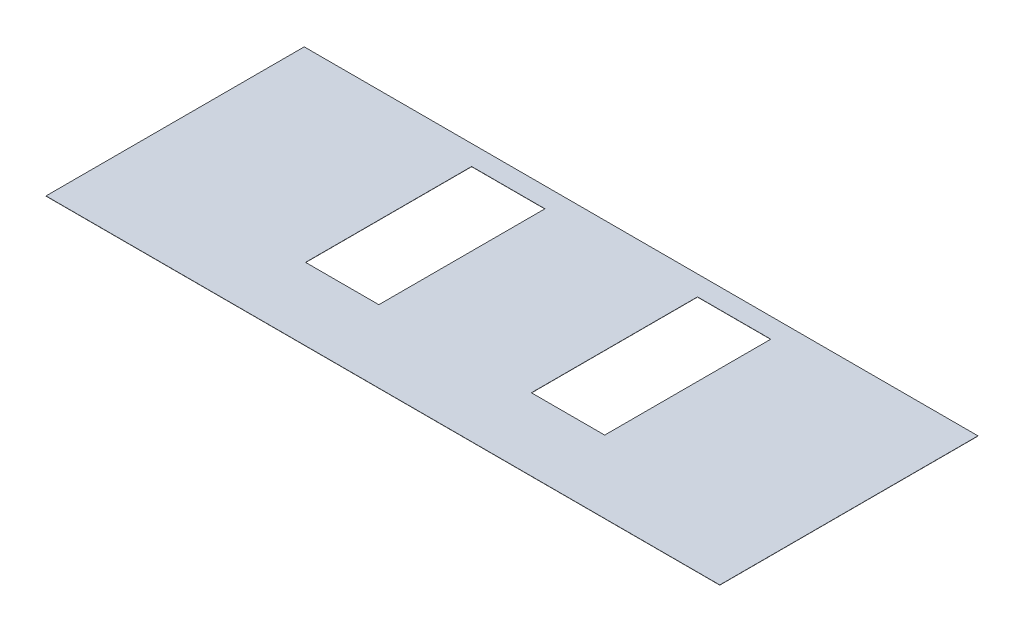
from build123d import *

# Parameters (mm, degrees)
SKETCH1_W               = 5486.4
SKETCH1_H               = 2102.612
BOSS_EXTRUDE1_DEPTH     = 1.5875
SKETCH2_W               = 596.9
SKETCH2_H               = 1352.55
CUT_EXTRUDE1_DEPTH      = 1
CUT_EXTRUDE1_DEPTH_BACK = 2.5875


with BuildPart() as part:
    # Sketch1 → Boss-Extrude1 (new body)
    with BuildSketch(Plane(origin=(0, 0, 0), x_dir=(1, 0, 0), z_dir=(0, 1, 0))):
        Rectangle(SKETCH1_W, SKETCH1_H)
    extrude(amount=BOSS_EXTRUDE1_DEPTH)

    # Sketch2 → Cut-Extrude1 (cut, two sides)
    with BuildSketch(Plane(origin=(0, 1.5875, 0), x_dir=(1, 0, 0), z_dir=(0, 1, 0))) as cut_extrude1_sk:
        with Locations((-919.48, 213.106)):
            Rectangle(SKETCH2_W, SKETCH2_H)
        with Locations((919.48, 213.106)):
            Rectangle(SKETCH2_W, SKETCH2_H)
    extrude(amount=CUT_EXTRUDE1_DEPTH, mode=Mode.SUBTRACT)
    extrude(cut_extrude1_sk.sketch, amount=-CUT_EXTRUDE1_DEPTH_BACK, mode=Mode.SUBTRACT)


solid = part.part
